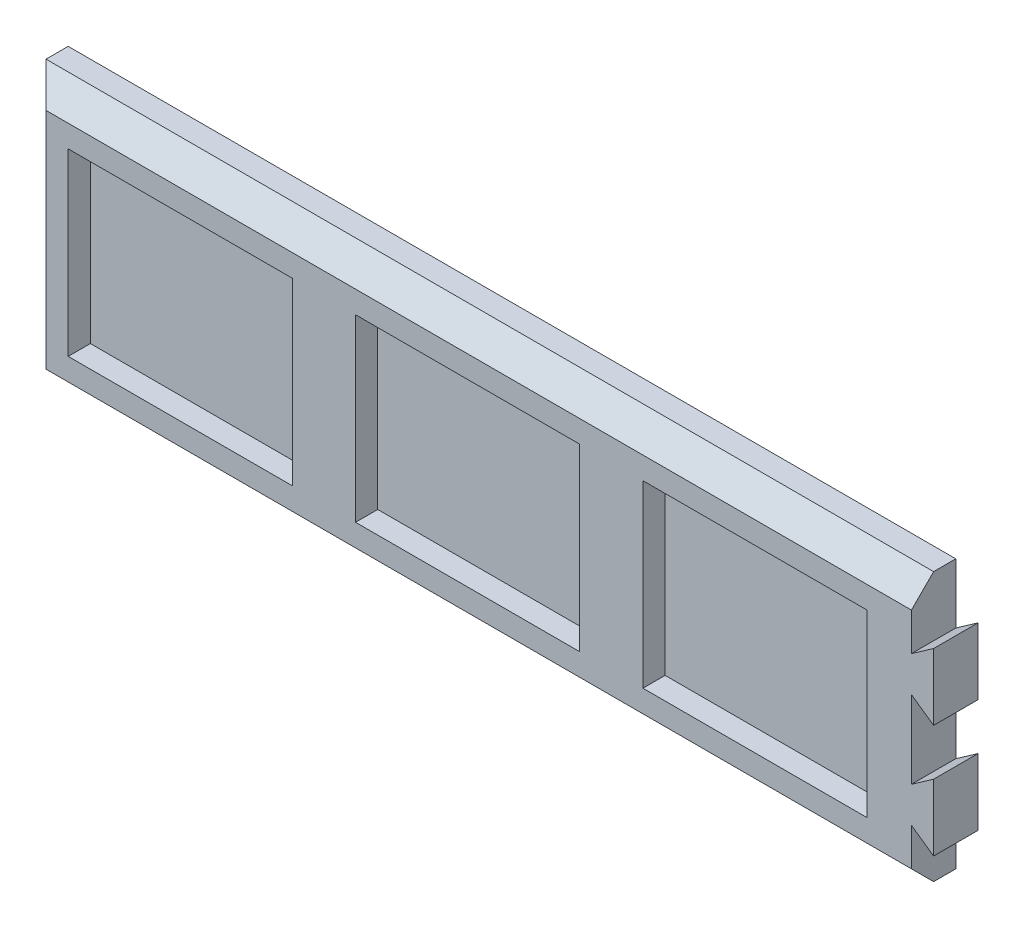
from build123d import *

# Parameters (mm, degrees)
SKIZZE1_W                       = 200
SKIZZE1_H                       = 60.5
AUFSATZ_LINEAR_AUSTRAGEN1_DEPTH = 10
SKIZZE2_W                       = 50.5
SKIZZE2_H                       = 40.5
SCHNITT_LINEAR_AUSTRAGEN1_DEPTH = 5
FASE1_SIZE                      = 5
AUFSATZ_LINEAR_AUSTRAGEN2_DEPTH = 10


with BuildPart() as part:
    # Skizze1 → Aufsatz-Linear austragen1 (new body)
    with BuildSketch(Plane.XY):
        with Locations((100, 0)):
            Rectangle(SKIZZE1_W, SKIZZE1_H)
    extrude(amount=AUFSATZ_LINEAR_AUSTRAGEN1_DEPTH)

    # Skizze2 → Schnitt-Linear austragen1 (cut)
    with BuildSketch(Plane.XY.offset(10)):
        with Locations((35.25, 0)):
            Rectangle(SKIZZE2_W, SKIZZE2_H)
        with Locations((100, 0)):
            Rectangle(SKIZZE2_W, SKIZZE2_H)
        with Locations((164.75, 0)):
            Rectangle(SKIZZE2_W, SKIZZE2_H)
    extrude(amount=-SCHNITT_LINEAR_AUSTRAGEN1_DEPTH, mode=Mode.SUBTRACT)

    # Fase1
    fase1_edges = [part.edges().sort_by_distance(p)[0] for p in [
        (100, 30.25, 10),
        (0, 0, 10),
        (100, -30.25, 10),
    ]]
    chamfer(fase1_edges, length=FASE1_SIZE)

    # Skizze3 → Aufsatz-Linear austragen2 (add)
    with BuildSketch(Plane.XY.offset(10)):
        Polygon((200, 16.75), (205, 20.25), (205, 5.25), (200, 8.75), align=None)
        Polygon((200, -8.75), (205, -5.25), (205, -20.25), (200, -16.75), align=None)
    extrude(amount=-AUFSATZ_LINEAR_AUSTRAGEN2_DEPTH)


solid = part.part
